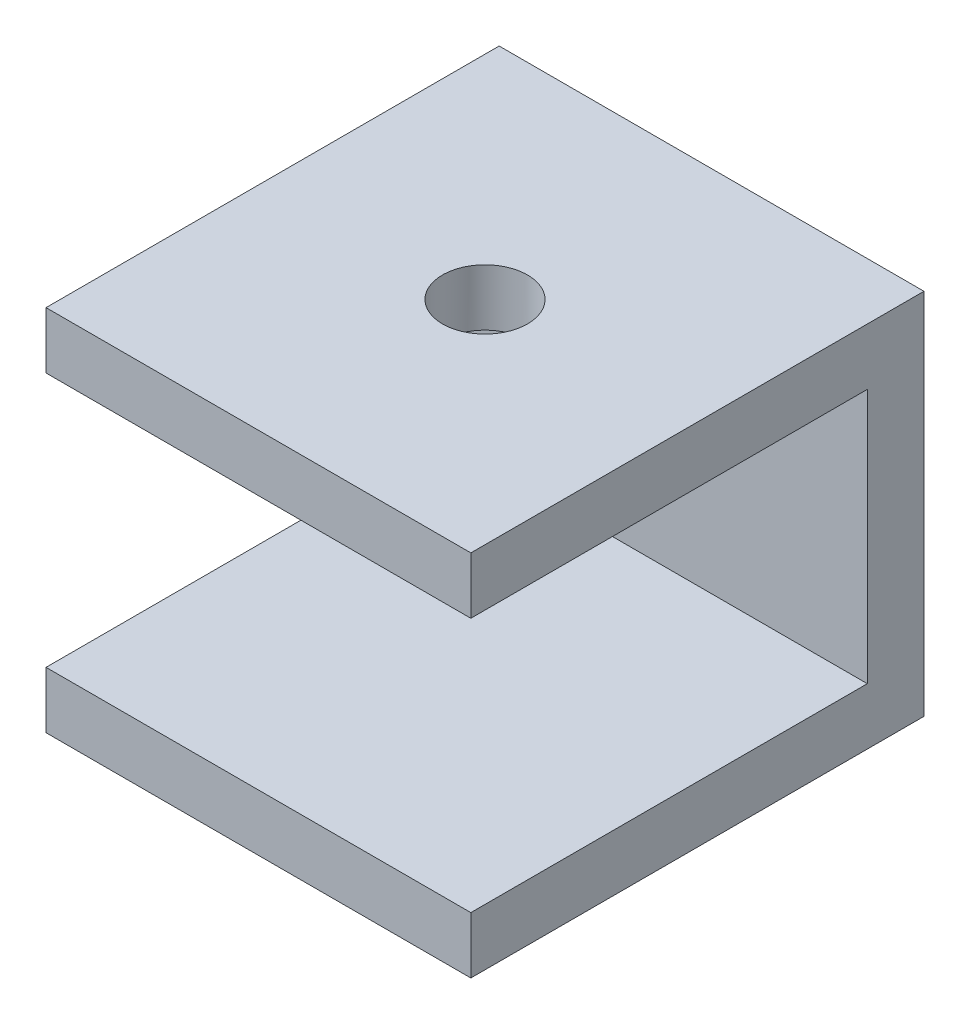
from build123d import *

# Parameters (mm, degrees)
BOSS_EXTRUDE1_DEPTH = 15
CUT_EXTRUDE1_REACH  = 15
SKETCH2_R           = 1.5


with BuildPart() as part:
    # Sketch1 → Boss-Extrude1 (new body)
    with BuildSketch(Plane(origin=(0, 0, 0), x_dir=(0, 0, -1), z_dir=(1, 0, 0))):
        Polygon((0, 0), (0, -13), (-16, -13), (-16, -11), (-2, -11), (-2, -2), (-16, -2), (-16, 0), align=None)
    extrude(amount=-BOSS_EXTRUDE1_DEPTH)

    # Sketch2 → Cut-Extrude1 (cut, up to next)
    with BuildSketch(Plane(origin=(0, 0, 0), x_dir=(1, 0, 0), z_dir=(0, 1, 0)), mode=Mode.PRIVATE) as cut_extrude1_sk1:
        with Locations((-7.5, -8)):
            Circle(SKETCH2_R)
    cut_extrude1_tool1 = extrude(cut_extrude1_sk1.sketch, amount=-CUT_EXTRUDE1_REACH, mode=Mode.PRIVATE) & part.part
    add(cut_extrude1_tool1.solids().sort_by_distance((-7.5, 0, 8))[0], mode=Mode.SUBTRACT)


solid = part.part
